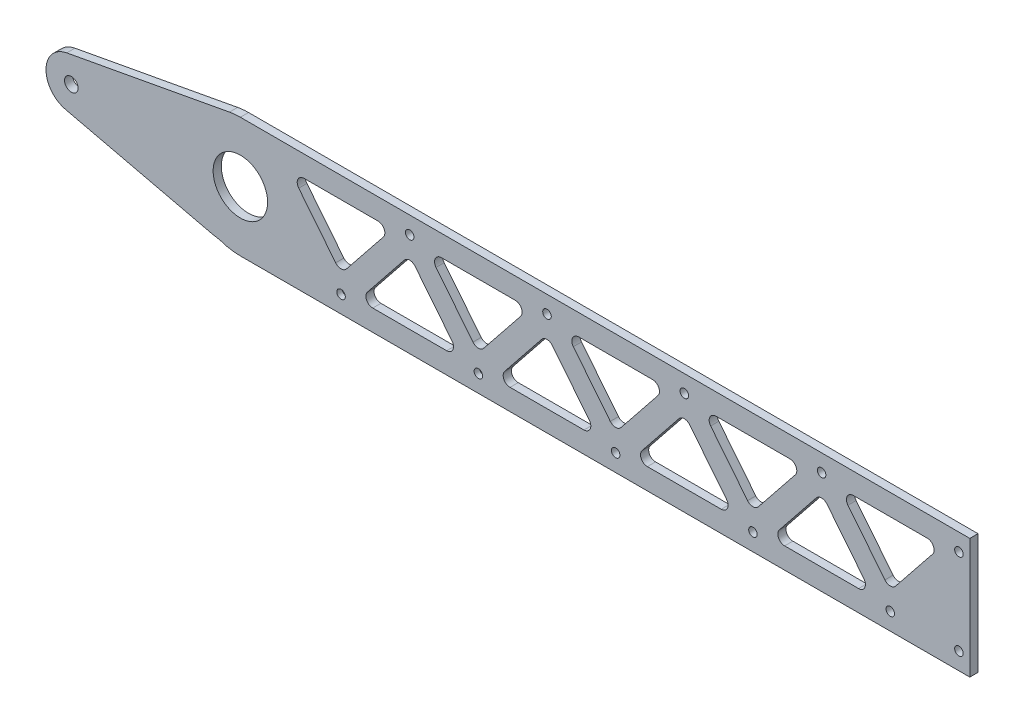
from build123d import *

# Parameters (mm, degrees)
SKETCH1_R                                       = 3.96875
SKETCH1_R_2                                     = 15.875
BOSS_EXTRUDE1_DEPTH                             = 4.7625
F_10_CLEARANCE_HOLE1_D                          = 4.9784
LPATTERN1_COUNT                                 = 4
LPATTERN1_PITCH                                 = 80
CUT_EXTRUDE1_DEPTH                              = 10
FILLET1_R                                       = 4
CUT_EXTRUDE2_DEPTH                              = 5.7625
FILLET2_R                                       = 4
LPATTERN2_COUNT                                 = 4
LPATTERN2_PITCH                                 = 80
FILLET1_OF_LPATTERN2_R                          = 4
LPATTERN3_COUNT                                 = 3
LPATTERN3_PITCH                                 = 80
FILLET2_OF_LPATTERN3_R                          = 4
LPATTERN4_COUNT                                 = 2
LPATTERN4_PITCH                                 = 80
FILLET2_OF_LPATTERN4_R                          = 4
LPATTERN5_COUNT                                 = 2
LPATTERN5_PITCH                                 = 80
FILLET1_OF_LPATTERN5_R                          = 4
F_10_CLEARANCE_HOLE2_D                          = 4.9784
F_10_CLEARANCE_HOLE2_DEPTH                      = 4.7625
CBORE_FOR_10_BUTTON_HEAD_CAP_SCREW1_D           = 4.9784
CBORE_FOR_10_BUTTON_HEAD_CAP_SCREW1_CBORE_D     = 6.35
CBORE_FOR_10_BUTTON_HEAD_CAP_SCREW1_CBORE_DEPTH = 1.5875


with BuildPart() as part:
    # Sketch1 → Boss-Extrude1 (new body)
    with BuildSketch(Plane.XY):
        with BuildLine():
            Line((212.5, 35), (-212.5, 35))
            ThreePointArc((-212.5, 35), (-215.694597401, 34.853902901), (-218.862525007, 34.416831283))
            Line((-218.862525007, 34.416831283), (-313.666145568, 16.890801601))
            ThreePointArc((-313.666145568, 16.890801601), (-325.748634462, 2.719438205), (-314.360273, -12.015530461))
            Line((-314.360273, -12.015530461), (-228.749110944, -32.134843328))
            Line((-228.749110944, -32.134843328), (-224.470705016, -32.889241728))
            ThreePointArc((-224.470705016, -32.889241728), (-218.577686218, -34.468271355), (-212.5, -35))
            Line((-212.5, -35), (212.5, -35))
            Line((212.5, -35), (212.5, 35))
        make_face()
        with Locations((-310.980775301, 2.364817767)):
            Circle(SKETCH1_R, mode=Mode.SUBTRACT)
        with Locations((-212.5, 0)):
            Circle(SKETCH1_R_2, mode=Mode.SUBTRACT)
    extrude(amount=BOSS_EXTRUDE1_DEPTH)

    # #10 Clearance Hole1 (through all)
    with Locations(Plane(origin=(0, 0, 0), x_dir=(-1, 0, 0), z_dir=(0, 0, -1))):
        with Locations((-126.15, 25), (-86.15, -25)):
            f_10_clearance_hole1 = Hole(F_10_CLEARANCE_HOLE1_D / 2)

    # LPattern1: #10 Clearance Hole1 ×4
    with Locations(*[(-i * LPATTERN1_PITCH, 0, 0) for i in range(1, LPATTERN1_COUNT)]):
        add(f_10_clearance_hole1, mode=Mode.SUBTRACT)

    # Sketch13 → Cut-Extrude1 (cut)
    with BuildSketch(Plane(origin=(0, 0, 0), x_dir=(-1, 0, 0), z_dir=(0, 0, -1))):
        Polygon((-56.301294523, 22.715958732), (-86.15, -14.594923114), (-115.998705477, 22.715958732), align=None)
    cut_extrude1 = extrude(amount=-CUT_EXTRUDE1_DEPTH, mode=Mode.SUBTRACT)

    # Fillet1
    fillet1_edges = [part.edges().sort_by_distance(p)[0] for p in [
        (56.301294523, 22.715958732, 2.38125),
        (86.15, -14.594923114, 2.38125),
        (115.998705477, 22.715958732, 2.38125),
    ]]
    fillet(fillet1_edges, radius=FILLET1_R)

    # Sketch14 → Cut-Extrude2 (cut, through all)
    with BuildSketch(Plane(origin=(0, 0, 0), x_dir=(-1, 0, 0), z_dir=(0, 0, -1))):
        Polygon((-46.15, 14.594923114), (-75.998705477, -22.715958732), (-16.301294523, -22.715958732), align=None)
    cut_extrude2 = extrude(amount=-CUT_EXTRUDE2_DEPTH, mode=Mode.SUBTRACT)

    # Fillet2
    fillet2_edges = [part.edges().sort_by_distance(p)[0] for p in [
        (46.15, 14.594923114, 2.38125),
        (16.301294523, -22.715958732, 2.38125),
        (75.998705477, -22.715958732, 2.38125),
    ]]
    fillet(fillet2_edges, radius=FILLET2_R)

    # LPattern2: Cut-Extrude1 ×4
    with Locations(*[(-i * LPATTERN2_PITCH, 0, 0) for i in range(1, LPATTERN2_COUNT)]):
        add(cut_extrude1, mode=Mode.SUBTRACT)

    # Fillet1 of LPattern2
    fillet1_of_lpattern2_edges = [part.edges().sort_by_distance(p)[0] for p in [
        (-23.698705477, 22.715958732, 2.38125),
        (6.15, -14.594923114, 2.38125),
        (35.998705477, 22.715958732, 2.38125),
        (-103.698705477, 22.715958732, 2.38125),
        (-73.85, -14.594923114, 2.38125),
        (-44.001294523, 22.715958732, 2.38125),
        (-183.698705477, 22.715958732, 2.38125),
        (-153.85, -14.594923114, 2.38125),
        (-124.001294523, 22.715958732, 2.38125),
    ]]
    fillet(fillet1_of_lpattern2_edges, radius=FILLET1_OF_LPATTERN2_R)

    # LPattern3: Cut-Extrude2 ×3
    with Locations(*[(-i * LPATTERN3_PITCH, 0, 0) for i in range(1, LPATTERN3_COUNT)]):
        add(cut_extrude2, mode=Mode.SUBTRACT)

    # Fillet2 of LPattern3
    fillet2_of_lpattern3_edges = [part.edges().sort_by_distance(p)[0] for p in [
        (-33.85, 14.594923114, 2.38125),
        (-63.698705477, -22.715958732, 2.38125),
        (-4.001294523, -22.715958732, 2.38125),
        (-113.85, 14.594923114, 2.38125),
        (-143.698705477, -22.715958732, 2.38125),
        (-84.001294523, -22.715958732, 2.38125),
    ]]
    fillet(fillet2_of_lpattern3_edges, radius=FILLET2_OF_LPATTERN3_R)

    # LPattern4: Cut-Extrude2 ×2
    with Locations(*[(i * LPATTERN4_PITCH, 0, 0) for i in range(1, LPATTERN4_COUNT)]):
        add(cut_extrude2, mode=Mode.SUBTRACT)

    # Fillet2 of LPattern4
    fillet2_of_lpattern4_edges = [part.edges().sort_by_distance(p)[0] for p in [
        (126.15, 14.594923114, 2.38125),
        (96.301294523, -22.715958732, 2.38125),
        (155.998705477, -22.715958732, 2.38125),
    ]]
    fillet(fillet2_of_lpattern4_edges, radius=FILLET2_OF_LPATTERN4_R)

    # LPattern5: Cut-Extrude1 ×2
    with Locations(*[(i * LPATTERN5_PITCH, 0, 0) for i in range(1, LPATTERN5_COUNT)]):
        add(cut_extrude1, mode=Mode.SUBTRACT)

    # Fillet1 of LPattern5
    fillet1_of_lpattern5_edges = [part.edges().sort_by_distance(p)[0] for p in [
        (136.301294523, 22.715958732, 2.38125),
        (166.15, -14.594923114, 2.38125),
        (195.998705477, 22.715958732, 2.38125),
    ]]
    fillet(fillet1_of_lpattern5_edges, radius=FILLET1_OF_LPATTERN5_R)

    # #10 Clearance Hole2
    with Locations(Plane.XY.offset(4.7625)):
        with Locations((206.15, 25), (206.15, -25), (166.15, -25)):
            Hole(F_10_CLEARANCE_HOLE2_D / 2, depth=F_10_CLEARANCE_HOLE2_DEPTH)

    # CBORE for #10 Button Head Cap Screw1 (through all)
    with Locations(Plane(origin=(0, 0, 0), x_dir=(-1, 0, 0), z_dir=(0, 0, -1))):
        with Locations((153.85, -25), (73.85, -25)):
            CounterBoreHole(CBORE_FOR_10_BUTTON_HEAD_CAP_SCREW1_D / 2, CBORE_FOR_10_BUTTON_HEAD_CAP_SCREW1_CBORE_D / 2, CBORE_FOR_10_BUTTON_HEAD_CAP_SCREW1_CBORE_DEPTH)


solid = part.part
